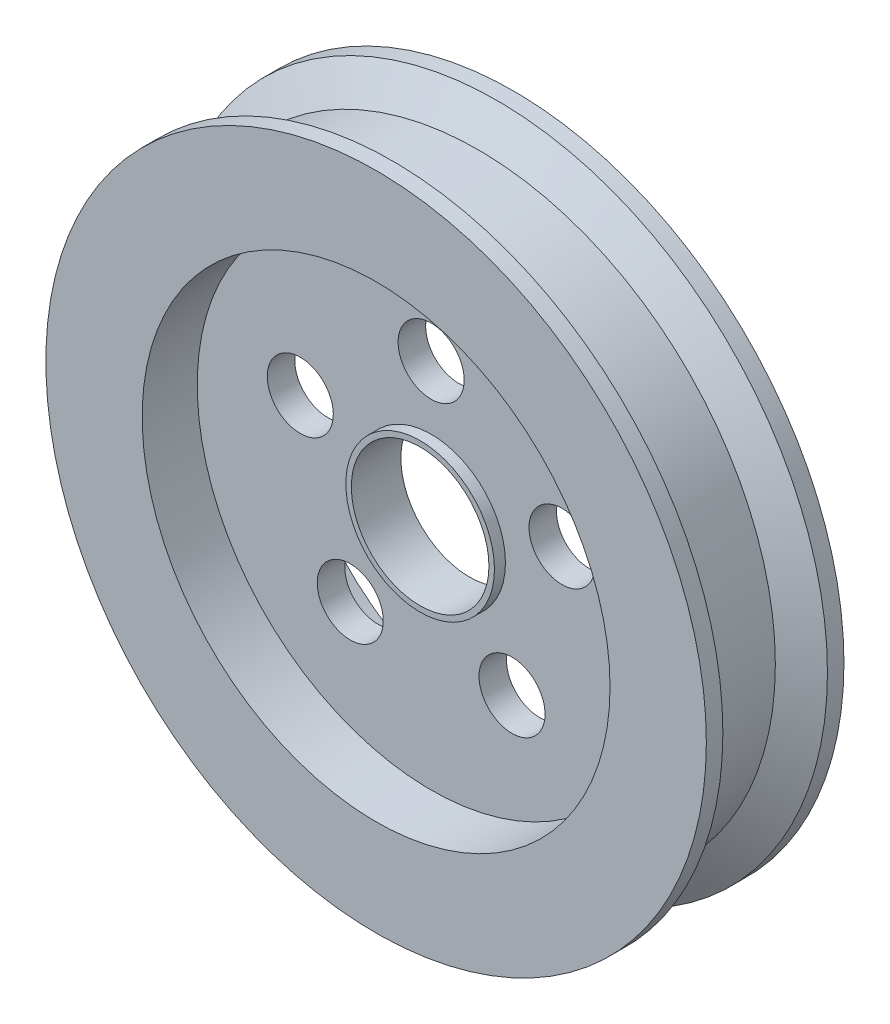
from build123d import *

# Parameters (mm, degrees)
SKETCH1_R                = 60
SKETCH1_R_2              = 12.5
BOSS_EXTRUDE1_DEPTH      = 12.5
SKETCH2_R                = 42.5
CUT_EXTRUDE1_DEPTH       = 10
SKETCH3_R                = 6
CUT_EXTRUDE2_DEPTH       = 16
CIRPATTERN1_COUNT        = 5
SKETCH5_R                = 13.5
SKETCH5_R_2              = 12.5
BOSS_EXTRUDE2_DEPTH      = 2
BOSS_EXTRUDE2_DEPTH_BACK = 7


with BuildPart() as part:
    # Sketch1 → Boss-Extrude1 (new body, symmetric)
    with BuildSketch(Plane.XY):
        Circle(SKETCH1_R)
        Circle(SKETCH1_R_2, mode=Mode.SUBTRACT)
    extrude(amount=BOSS_EXTRUDE1_DEPTH, both=True)

    # Sketch2 → Cut-Extrude1 (cut)
    with BuildSketch(Plane.XY.offset(12.5)):
        Circle(SKETCH2_R)
    cut_extrude1 = extrude(amount=-CUT_EXTRUDE1_DEPTH, mode=Mode.SUBTRACT)

    # Mirror1: Cut-Extrude1 across plane
    add(cut_extrude1.mirror(Plane.XY), mode=Mode.SUBTRACT)

    # Sketch3 → Cut-Extrude2 (cut, through all)
    with BuildSketch(Plane.XY.offset(2.5)):
        with Locations((0, 25)):
            Circle(SKETCH3_R)
    cut_extrude2 = extrude(amount=-CUT_EXTRUDE2_DEPTH, mode=Mode.SUBTRACT)

    # CirPattern1: Cut-Extrude2 ×5 about axis
    cirpattern1_axis = Axis((0, 0, 0), (0, 0, 1))
    for i in range(1, CIRPATTERN1_COUNT):
        add(cut_extrude2.rotate(cirpattern1_axis, i * 360 / CIRPATTERN1_COUNT), mode=Mode.SUBTRACT)

    # Sketch4 → Cut-Revolve1 (revolve, cut)
    with BuildSketch(Plane(origin=(0, 0, 0), x_dir=(1, 0, 0), z_dir=(0, 1, 0))):
        Polygon((60, 9.5), (54, 6.035898385), (54, -6.035898385), (60, -9.5), align=None)
    revolve(axis=Axis((0, 0, 0), (0, 0, -1)), mode=Mode.SUBTRACT)

    # Sketch5 → Boss-Extrude2 (add, two sides)
    with BuildSketch(Plane.XY.offset(2.5)) as boss_extrude2_sk:
        Circle(SKETCH5_R)
        Circle(SKETCH5_R_2, mode=Mode.SUBTRACT)
    extrude(amount=BOSS_EXTRUDE2_DEPTH)
    extrude(boss_extrude2_sk.sketch, amount=-BOSS_EXTRUDE2_DEPTH_BACK)


solid = part.part
